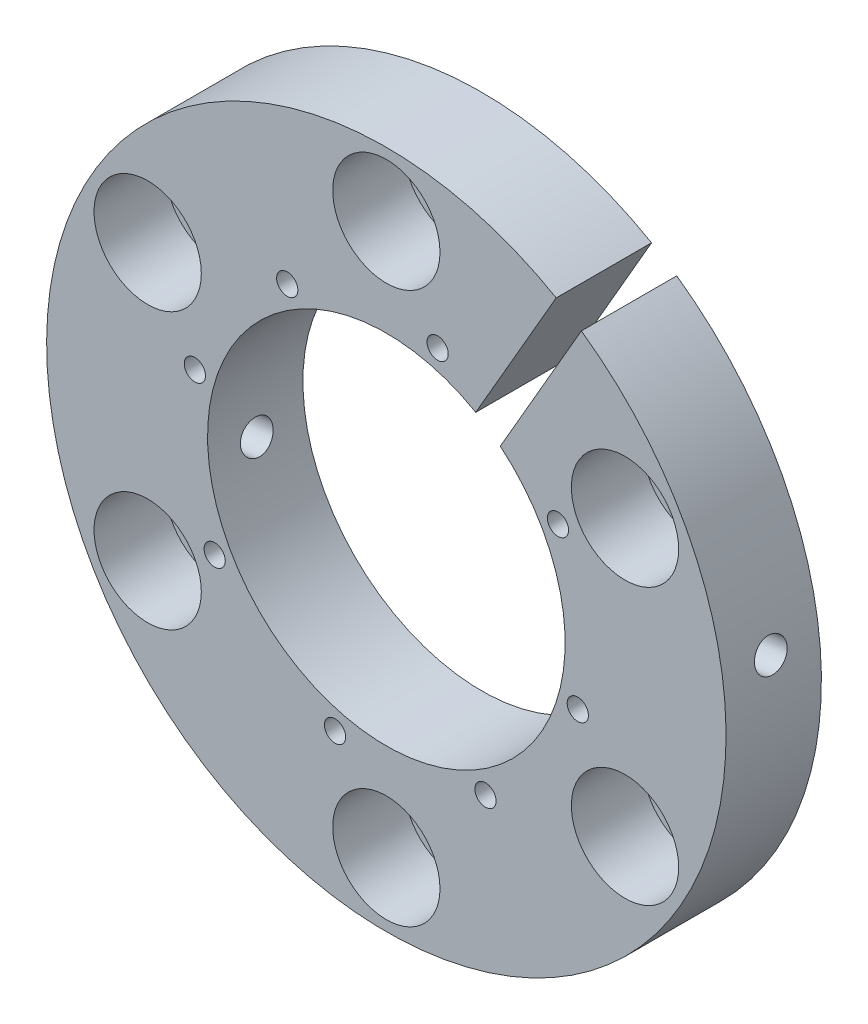
from build123d import *

# Parameters (mm, degrees)
SKETCH2_R                                = 36.195
BOSS_EXTRUDE1_DEPTH                      = 10.16
SKETCH3_R                                = 19.05
CUT_EXTRUDE1_DEPTH                       = 11.16
CBORE_FOR_1_4_HEX_HEAD_BOLT1_D           = 6.7564
CBORE_FOR_1_4_HEX_HEAD_BOLT1_CBORE_D     = 11.43
CBORE_FOR_1_4_HEX_HEAD_BOLT1_CBORE_DEPTH = 7.62
CIRPATTERN1_COUNT                        = 6
CIRPATTERN5_COUNT                        = 8
CUT_EXTRUDE9_DEPTH                       = 11.16
F_8_32_TAPPED_HOLE3_D                    = 3.4544


with BuildPart() as part:
    # Sketch2 → Boss-Extrude1 (new body)
    with BuildSketch(Plane.XY):
        Circle(SKETCH2_R)
    extrude(amount=BOSS_EXTRUDE1_DEPTH)

    # Sketch3 → Cut-Extrude1 (cut, through all)
    with BuildSketch(Plane.XY.offset(10.16)):
        Circle(SKETCH3_R)
    extrude(amount=-CUT_EXTRUDE1_DEPTH, mode=Mode.SUBTRACT)

    # CBORE for 1_4 Hex Head Bolt1 (through all)
    with Locations(Plane.XY.offset(10.16)):
        with Locations((0, 29.3624)):
            cbore_for_1_4_hex_head_bolt1 = CounterBoreHole(CBORE_FOR_1_4_HEX_HEAD_BOLT1_D / 2, CBORE_FOR_1_4_HEX_HEAD_BOLT1_CBORE_D / 2, CBORE_FOR_1_4_HEX_HEAD_BOLT1_CBORE_DEPTH)

    # CirPattern1: CBORE for 1_4 Hex Head Bolt1 ×6 about axis
    cirpattern1_axis = Axis((0, 0, 0), (0, 0, 1))
    for i in range(1, CIRPATTERN1_COUNT):
        add(cbore_for_1_4_hex_head_bolt1.rotate(cirpattern1_axis, i * 360 / CIRPATTERN1_COUNT), mode=Mode.SUBTRACT)

    # Sketch35 → 4-40 Tapped Hole1 (revolve, cut)
    with BuildSketch(Plane(origin=(5.465977373, 20.39930527, 10.16), x_dir=(0, -1, 0), z_dir=(1, 0, 0))):
        Polygon((0, 0), (0, 8.299152758), (1.1303, 7.62), (1.1303, 0), align=None)
    f_4_40_tapped_hole1 = revolve(axis=Axis((5.465977373, 20.39930527, 16.51), (0, 0, -1)), mode=Mode.SUBTRACT)

    # CirPattern5: 4-40 Tapped Hole1 ×8 about axis
    cirpattern5_axis = Axis((0, 0, 0), (0, 0, 1))
    for i in range(1, CIRPATTERN5_COUNT):
        add(f_4_40_tapped_hole1.rotate(cirpattern5_axis, i * 360 / CIRPATTERN5_COUNT), mode=Mode.SUBTRACT)

    # Sketch44 → Cut-Extrude9 (cut, through all)
    with BuildSketch(Plane.XY.offset(10.16)):
        Polygon((0, 0), (22.496225018, 38.964604709), (25.245855675, 37.377104709), (2.749630657, -1.5875), align=None)
    extrude(amount=-CUT_EXTRUDE9_DEPTH, mode=Mode.SUBTRACT)

    # 8-32 Tapped Hole3 (through all)
    with Locations(Plane(origin=(-35.885346757, -4.724395527, 5.08), x_dir=(0.130526192, -0.991444861, 0), z_dir=(-0.991444861, -0.130526192, 0))):
        with Locations((0, 0)):
            Hole(F_8_32_TAPPED_HOLE3_D / 2)


solid = part.part
